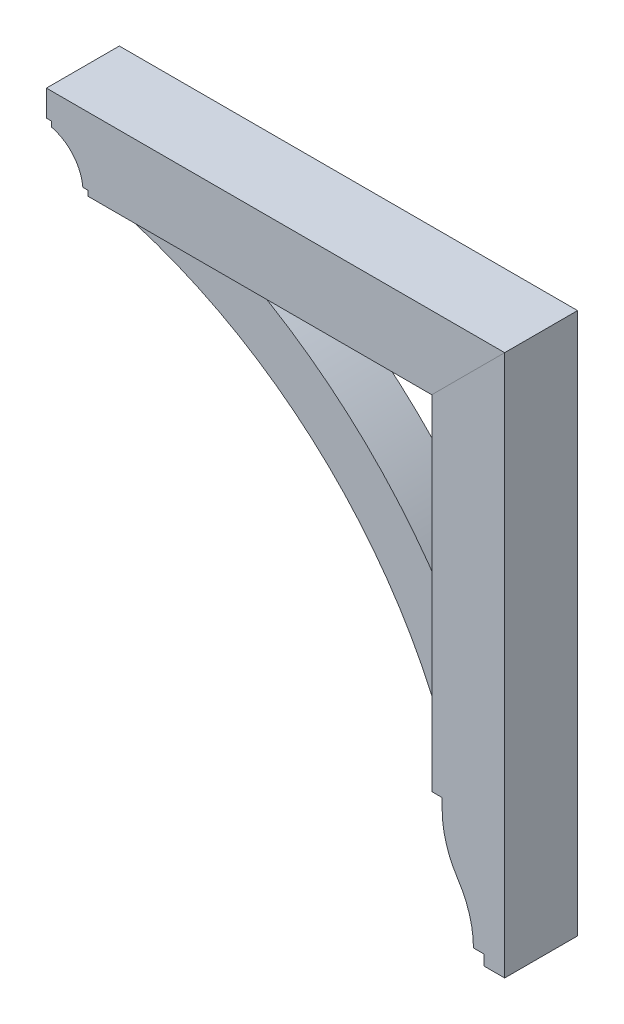
from build123d import *

# Parameters (mm, degrees)
BOSS_EXTRUDE1_DEPTH = 44.45
BOSS_EXTRUDE2_DEPTH = 31.75
BOSS_EXTRUDE3_DEPTH = 44.45


with BuildPart() as part:
    # Sketch1 → Boss-Extrude1 (new body, symmetric)
    with BuildSketch(Plane.XY):
        with BuildLine():
            Line((-229.368776984, 286.385), (-229.368776984, 292.735))
            Line((-229.368776984, 292.735), (-235.718776984, 292.735))
            Line((-235.718776984, 292.735), (-235.718776984, 324.485))
            Line((-235.718776984, 324.485), (323.081223016, 324.485))
            Line((323.081223016, 324.485), (234.181223016, 235.585))
            Line((234.181223016, 235.585), (-184.918776984, 235.585))
            Line((-184.918776984, 235.585), (-184.918776984, 241.935))
            Line((-184.918776984, 241.935), (-191.268776984, 241.935))
            ThreePointArc((-191.268776984, 241.935), (-203.260423906, 270.210016924), (-229.368776984, 286.385))
        make_face()
    extrude(amount=BOSS_EXTRUDE1_DEPTH, both=True)


with BuildPart() as body_2:
    # Sketch1_3 → Boss-Extrude2 (new body, symmetric)
    with BuildSketch(Plane.XY):
        with BuildLine():
            ThreePointArc((234.181223016, 18.0975), (129.683318975, 141.818301445), (-2.356276984, 235.585))
            Line((-2.356276984, 235.585), (-140.468776984, 235.585))
            Line((-140.468776984, 235.585), (-140.468776984, 222.885))
            ThreePointArc((-140.468776984, 222.885), (75.044638848, 103.508794049), (221.481223016, -94.615))
            Line((221.481223016, -94.615), (234.181223016, -94.615))
            Line((234.181223016, -94.615), (234.181223016, 18.0975))
        make_face()
    extrude(amount=BOSS_EXTRUDE2_DEPTH, both=True)


with BuildPart() as body_3:
    # Sketch1_4 → Boss-Extrude3 (new body, symmetric)
    with BuildSketch(Plane.XY):
        with BuildLine():
            Line((323.081223016, -335.915), (323.081223016, 324.485))
            Line((323.081223016, 324.485), (234.181223016, 235.585))
            Line((234.181223016, 235.585), (234.181223016, -183.515))
            Line((234.181223016, -183.515), (246.881223016, -183.515))
            Line((246.881223016, -183.515), (246.881223016, -196.215))
            ThreePointArc((246.881223016, -196.215), (251.768629387, -229.515028089), (266.018608337, -260.006284404))
            ThreePointArc((266.018608337, -260.006284404), (280.138450492, -290.219081757), (284.981223016, -323.215))
            Line((284.981223016, -323.215), (297.681223016, -323.215))
            Line((297.681223016, -323.215), (297.681223016, -335.915))
            Line((297.681223016, -335.915), (323.081223016, -335.915))
        make_face()
    extrude(amount=BOSS_EXTRUDE3_DEPTH, both=True)


solid = Compound([part.part, body_2.part, body_3.part])
